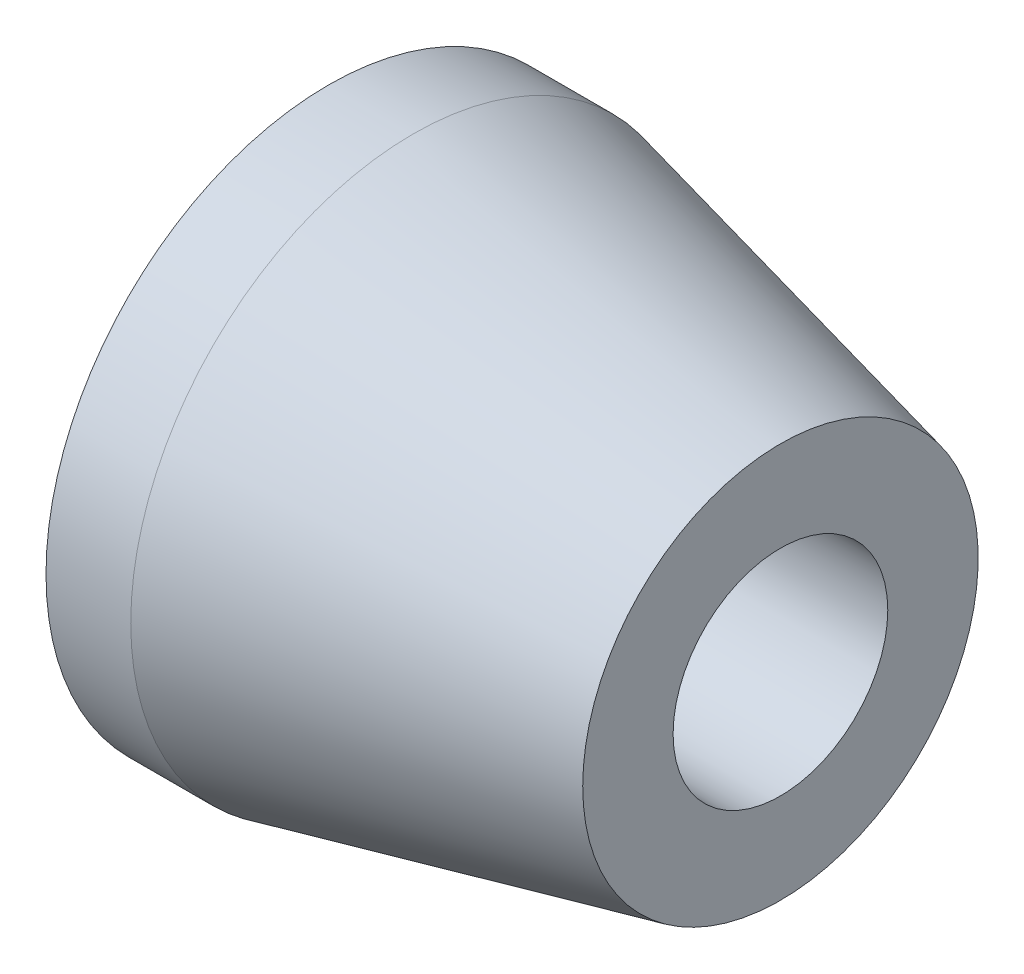
from build123d import *

# Parameters (mm, degrees)
SKETCH1_R           = 10
BOSS_EXTRUDE1_DEPTH = 3
SKETCH2_R           = 5.5
CUT_EXTRUDE1_DEPTH  = 2
SKETCH3_R           = 7
SKETCH4_R           = 3.8
CUT_EXTRUDE2_DEPTH  = 14


with BuildPart() as part:
    # Sketch1 → Boss-Extrude1 (new body)
    with BuildSketch(Plane(origin=(0, 0, 0), x_dir=(0, 0, -1), z_dir=(1, 0, 0))):
        Circle(SKETCH1_R)
    extrude(amount=BOSS_EXTRUDE1_DEPTH)

    # Sketch2 → Cut-Extrude1 (cut)
    with BuildSketch(Plane.ZY):
        Circle(SKETCH2_R)
    extrude(amount=-CUT_EXTRUDE1_DEPTH, mode=Mode.SUBTRACT)

    # Sketch3 → section 0 of loft1
    with BuildSketch(Plane.ZY.offset(-16), mode=Mode.PRIVATE) as loft1_s0:
        Circle(SKETCH3_R)
    # loft up to a face of the part (loft1)
    loft([loft1_s0.sketch, Face(Wire([part.edges().sort_by_distance((3, 7.289686274, 6.845471059))[0]]))])

    # Sketch4 → Cut-Extrude2 (cut)
    with BuildSketch(Plane(origin=(16, 0, 0), x_dir=(0, 0, -1), z_dir=(1, 0, 0))):
        Circle(SKETCH4_R)
    extrude(amount=-CUT_EXTRUDE2_DEPTH, mode=Mode.SUBTRACT)


solid = part.part
